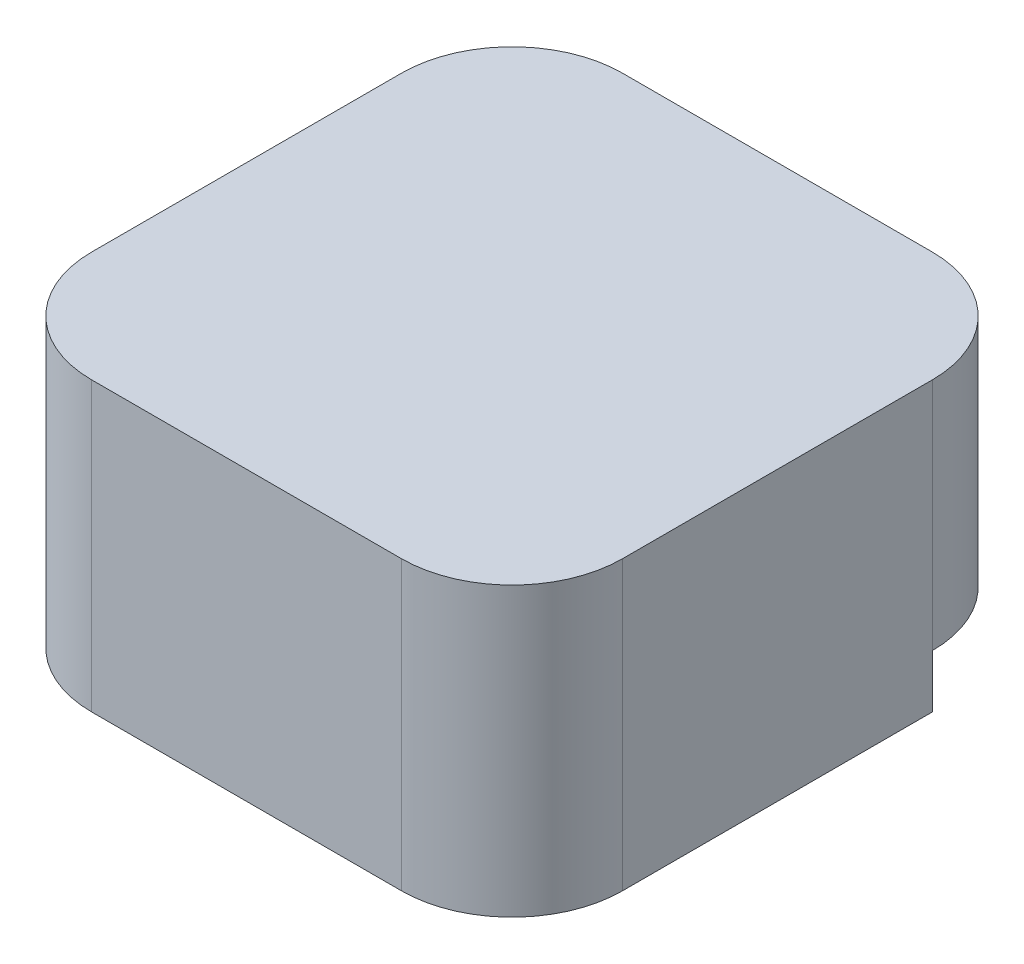
from build123d import *

# Parameters (mm, degrees)
SKICA1_W                 = 12
SKICA1_H                 = 12
SKICA1_W_2               = 4.1
SKICA1_H_2               = 4.1
P_IDAT_VYSUNUT_M1_DEPTH  = 2.5
SKICA2_W                 = 12
SKICA2_H                 = 12
P_IDAT_VYSUNUT_M2_DEPTH  = 4
ZAOBLIT1_R               = 2.5
SKICA3_W                 = 3
SKICA3_H                 = 1.2
ODEBRAT_VYSUNUT_M1_DEPTH = 13


with BuildPart() as part:
    # Skica1 → Přidat vysunutím1 (new body)
    with BuildSketch(Plane(origin=(0, 0, 0), x_dir=(1, 0, 0), z_dir=(0, 1, 0))):
        with Locations((6, 6)):
            Rectangle(SKICA1_W, SKICA1_H)
        with Locations((6, 6)):
            Rectangle(SKICA1_W_2, SKICA1_H_2, mode=Mode.SUBTRACT)
    extrude(amount=P_IDAT_VYSUNUT_M1_DEPTH)

    # Skica2 → Přidat vysunutím2 (add)
    with BuildSketch(Plane(origin=(0, 2.5, 0), x_dir=(1, 0, 0), z_dir=(0, 1, 0))):
        with Locations((6, 6)):
            Rectangle(SKICA2_W, SKICA2_H)
    extrude(amount=P_IDAT_VYSUNUT_M2_DEPTH)

    # Zaoblit1
    zaoblit1_edges = [part.edges().sort_by_distance(p)[0] for p in [
        (0, 3.25, -12),
        (12, 3.25, -12),
        (12, 3.25, 0),
        (0, 3.25, 0),
    ]]
    fillet(zaoblit1_edges, radius=ZAOBLIT1_R)

    # Skica3 → Odebrat vysunutím1 (cut, through all)
    with BuildSketch(Plane(origin=(12, 0, 0), x_dir=(0, 0, -1), z_dir=(1, 0, 0))):
        with Locations((11, 0.6)):
            Rectangle(SKICA3_W, SKICA3_H)
    extrude(amount=-ODEBRAT_VYSUNUT_M1_DEPTH, mode=Mode.SUBTRACT)


solid = part.part
